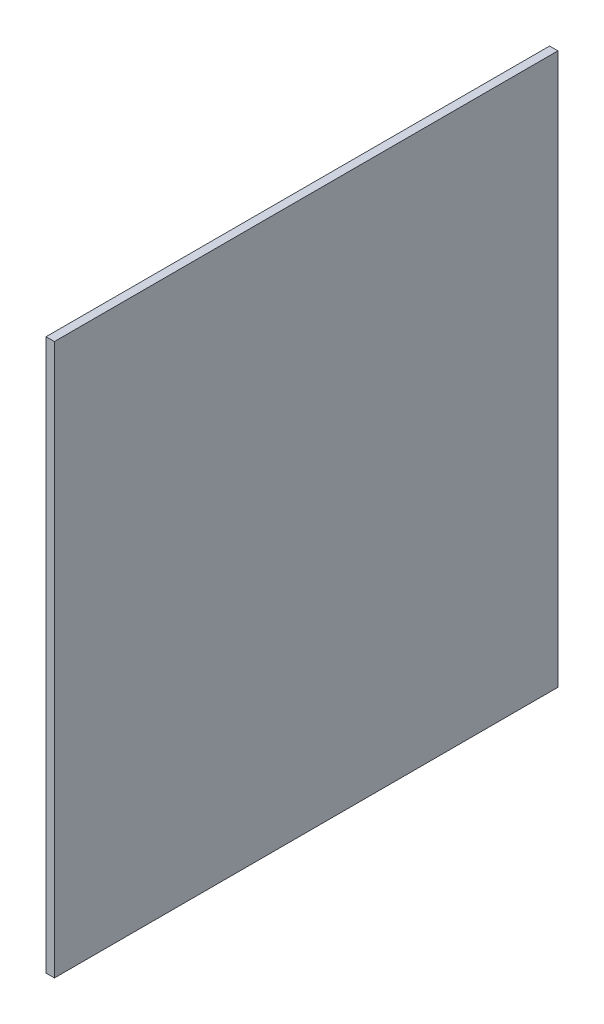
from build123d import *

# Parameters (mm, degrees)
SKETCH1_W           = 12.7
SKETCH1_H           = 765.692490037
BOSS_EXTRUDE1_DEPTH = 838.2


with BuildPart() as part:
    # Sketch1 → Boss-Extrude1 (new body)
    with BuildSketch(Plane(origin=(0, -457.2, 0), x_dir=(1, 0, 0), z_dir=(0, 1, 0))):
        with Locations((2241.55, -12.359164896)):
            Rectangle(SKETCH1_W, SKETCH1_H)
    extrude(amount=BOSS_EXTRUDE1_DEPTH)


solid = part.part
